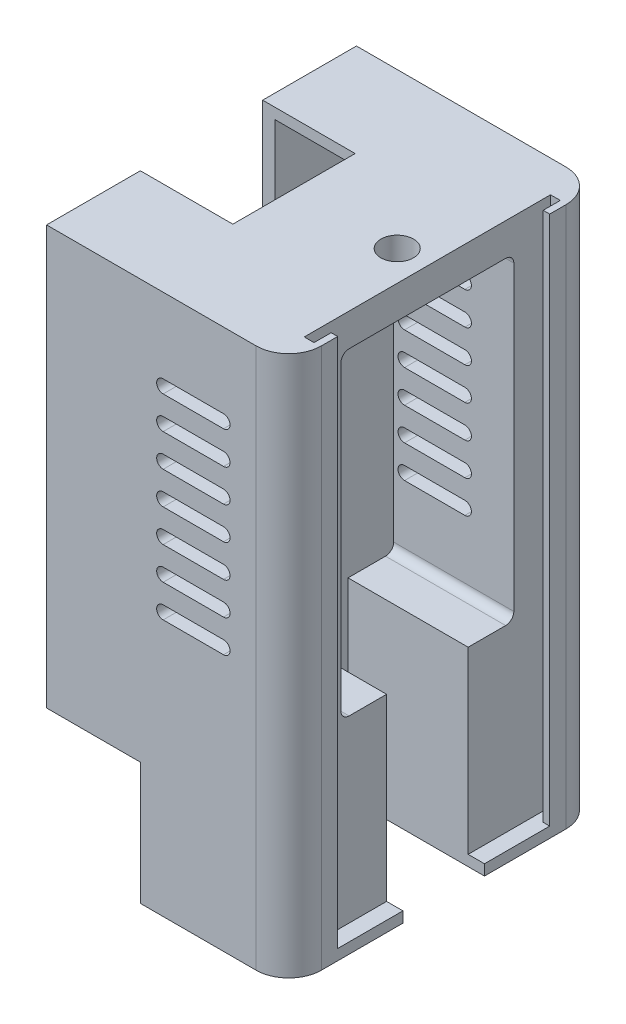
from build123d import *

# Parameters (mm, degrees)
SKETCH1_W                = 37.719
SKETCH1_H                = 84.214152012
BOSS_EXTRUDE1_DEPTH      = 1.905
BOSS_EXTRUDE1_DEPTH_BACK = 46.355
SKETCH3_W                = 14.605
SKETCH3_H                = 19.05
CUT_EXTRUDE1_DEPTH       = 49.26
CUT_EXTRUDE2_DEPTH       = 65.405
CUT_EXTRUDE3_REACH       = 39.719
SKETCH6_W                = 12.7
SKETCH6_H                = 44.45
CUT_EXTRUDE4_DEPTH       = 63.5
CUT_EXTRUDE5_DEPTH       = 21.2471
SKETCH8_R                = 1.016
BOSS_EXTRUDE2_DEPTH      = 6.35
FILLET1_R                = 1.27
CUT_EXTRUDE7_DEPTH       = 82.55
FILLET2_R                = 5.08
CUT_EXTRUDE8_DEPTH       = 38.592
CUT_EXTRUDE8_DEPTH_BACK  = 11.668
CUT_EXTRUDE9_REACH       = 86.214
SKETCH12_R               = 2.54


with BuildPart() as part:
    # Sketch1 → Boss-Extrude1 (new body, two sides)
    with BuildSketch(Plane.XY) as boss_extrude1_sk:
        with Locations((18.8595, -42.107076006)):
            Rectangle(SKETCH1_W, SKETCH1_H)
    extrude(amount=BOSS_EXTRUDE1_DEPTH)
    extrude(boss_extrude1_sk.sketch, amount=-BOSS_EXTRUDE1_DEPTH_BACK)

    # Sketch3 → Cut-Extrude1 (cut, through all)
    with BuildSketch(Plane.XY.offset(1.905)):
        with Locations((7.3025, -74.689152012)):
            Rectangle(SKETCH3_W, SKETCH3_H)
    extrude(amount=-CUT_EXTRUDE1_DEPTH, mode=Mode.SUBTRACT)

    # Sketch4 → Cut-Extrude2 (cut)
    with BuildSketch(Plane(origin=(0, 0, 0), x_dir=(1, 0, 0), z_dir=(0, 1, 0))):
        Polygon((1.905, 22.225), (1.905, 31.75), (14.405235248, 31.75), (14.405235248, 12.7), (1.905, 12.7), align=None)
    extrude(amount=-CUT_EXTRUDE2_DEPTH, mode=Mode.SUBTRACT)

    # Sketch5 → Cut-Extrude3 (cut, up to next)
    with BuildSketch(Plane.ZY, mode=Mode.PRIVATE) as cut_extrude3_sk1:
        Polygon((-22.225, 0), (-12.7, 0), (-12.7, -38.1), (-31.75, -38.1), (-31.75, 0), align=None)
    cut_extrude3_tool1 = extrude(cut_extrude3_sk1.sketch, amount=-CUT_EXTRUDE3_REACH, mode=Mode.PRIVATE) & part.part
    add(cut_extrude3_tool1.solids().sort_by_distance((0, -19.05, -22.225))[0], mode=Mode.SUBTRACT)

    # Sketch6 → Cut-Extrude4 (cut)
    with BuildSketch(Plane.XZ.offset(65.164152012)):
        with Locations((8.255, -22.225)):
            Rectangle(SKETCH6_W, SKETCH6_H)
    extrude(amount=-CUT_EXTRUDE4_DEPTH, mode=Mode.SUBTRACT)

    # Sketch7 → Cut-Extrude5 (cut)
    with BuildSketch(Plane(origin=(37.719, 0, 0), x_dir=(0, 0, -1), z_dir=(1, 0, 0))):
        Polygon((22.225, -5.08), (35.687, -5.08), (35.687, -54.61), (28.575, -54.61), (28.575, -84.214152012), (15.875, -84.214152012), (15.875, -54.61), (8.763, -54.61), (8.763, -5.08), align=None)
    extrude(amount=-CUT_EXTRUDE5_DEPTH, mode=Mode.SUBTRACT)

    # Sketch8 → Boss-Extrude2 (add)
    with BuildSketch(Plane(origin=(16.4719, 0, 0), x_dir=(0, 0, -1), z_dir=(1, 0, 0))):
        with Locations((33.655, -7.62)):
            Circle(SKETCH8_R)
        with Locations((10.795, -7.62)):
            Circle(SKETCH8_R)
    extrude(amount=BOSS_EXTRUDE2_DEPTH)

    # Fillet1
    fillet1_edges = [part.edges().sort_by_distance(p)[0] for p in [
        (27.09545, -5.08, -8.763),
        (27.09545, -5.08, -35.687),
        (27.09545, -54.61, -35.687),
        (27.09545, -54.61, -8.763),
    ]]
    fillet(fillet1_edges, radius=FILLET1_R)

    # Sketch9 → Cut-Extrude7 (cut)
    with BuildSketch(Plane(origin=(0, 0, 0), x_dir=(1, 0, 0), z_dir=(0, 1, 0))):
        Polygon((36.703, 41.402), (35.179, 41.402), (35.179, 3.048), (36.703, 3.048), (36.703, 5.715), (37.719, 5.715), (37.719, 22.225), (37.719, 38.735), (36.703, 38.735), align=None)
    extrude(amount=-CUT_EXTRUDE7_DEPTH, mode=Mode.SUBTRACT)

    # Fillet2
    fillet2_edges = [part.edges().sort_by_distance(p)[0] for p in [
        (37.719, -42.107076006, -46.355),
        (37.719, -42.107076006, 1.905),
    ]]
    fillet(fillet2_edges, radius=FILLET2_R)

    # Sketch10 → Cut-Extrude8 (cut, two sides)
    with BuildSketch(Plane.XY.offset(-35.687)) as cut_extrude8_sk:
        with BuildLine():
            Line((27.559, -13.716), (18.161, -13.716))
            ThreePointArc((18.161, -13.716), (17.145, -12.7), (18.161, -11.684))
            Line((18.161, -11.684), (27.559, -11.684))
            ThreePointArc((27.559, -11.684), (28.575, -12.7), (27.559, -13.716))
        make_face()
        with BuildLine():
            Line((27.559, -18.796), (18.161, -18.796))
            ThreePointArc((18.161, -18.796), (17.145, -17.78), (18.161, -16.764))
            Line((18.161, -16.764), (27.559, -16.764))
            ThreePointArc((27.559, -16.764), (28.575, -17.78), (27.559, -18.796))
        make_face()
        with BuildLine():
            Line((27.559, -23.876), (18.161, -23.876))
            ThreePointArc((18.161, -23.876), (17.145, -22.86), (18.161, -21.844))
            Line((18.161, -21.844), (27.559, -21.844))
            ThreePointArc((27.559, -21.844), (28.575, -22.86), (27.559, -23.876))
        make_face()
        with BuildLine():
            Line((27.559, -28.956), (18.161, -28.956))
            ThreePointArc((18.161, -28.956), (17.145, -27.94), (18.161, -26.924))
            Line((18.161, -26.924), (27.559, -26.924))
            ThreePointArc((27.559, -26.924), (28.575, -27.94), (27.559, -28.956))
        make_face()
        with BuildLine():
            Line((27.559, -34.036), (18.161, -34.036))
            ThreePointArc((18.161, -34.036), (17.145, -33.02), (18.161, -32.004))
            Line((18.161, -32.004), (27.559, -32.004))
            ThreePointArc((27.559, -32.004), (28.575, -33.02), (27.559, -34.036))
        make_face()
        with BuildLine():
            Line((27.559, -39.116), (18.161, -39.116))
            ThreePointArc((18.161, -39.116), (17.145, -38.1), (18.161, -37.084))
            Line((18.161, -37.084), (27.559, -37.084))
            ThreePointArc((27.559, -37.084), (28.575, -38.1), (27.559, -39.116))
        make_face()
        with BuildLine():
            Line((27.559, -44.196), (18.161, -44.196))
            ThreePointArc((18.161, -44.196), (17.145, -43.18), (18.161, -42.164))
            Line((18.161, -42.164), (27.559, -42.164))
            ThreePointArc((27.559, -42.164), (28.575, -43.18), (27.559, -44.196))
        make_face()
    extrude(amount=CUT_EXTRUDE8_DEPTH, mode=Mode.SUBTRACT)
    extrude(cut_extrude8_sk.sketch, amount=-CUT_EXTRUDE8_DEPTH_BACK, mode=Mode.SUBTRACT)

    # Sketch12 → Cut-Extrude9 (cut, up to next)
    with BuildSketch(Plane(origin=(0, 0, 0), x_dir=(1, 0, 0), z_dir=(0, 1, 0)), mode=Mode.PRIVATE) as cut_extrude9_sk1:
        with Locations((30.48, 22.225)):
            Circle(SKETCH12_R)
    cut_extrude9_tool1 = extrude(cut_extrude9_sk1.sketch, amount=-CUT_EXTRUDE9_REACH, mode=Mode.PRIVATE) & part.part
    add(cut_extrude9_tool1.solids().sort_by_distance((30.48, 0, -22.225))[0], mode=Mode.SUBTRACT)


solid = part.part
